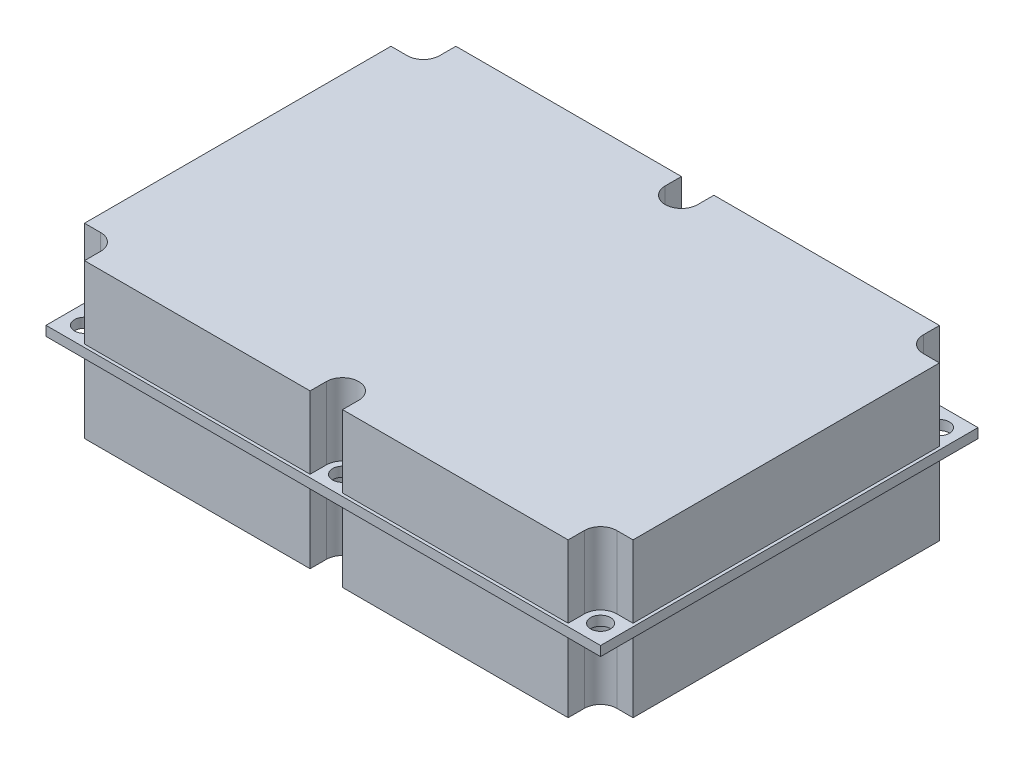
from build123d import *

# Parameters (mm, degrees)
SKETCH1_W            = 91.44
SKETCH1_H            = 62.23
BOSS_EXTRUDE1_DEPTH  = 0.79375
SKETCH3_R            = 1.6383
CUT_EXTRUDE1_DEPTH   = 1.79375
LPATTERN1_COUNT      = 3
LPATTERN1_PITCH      = 42.545
LPATTERN1_COUNT_DIR2 = 2
LPATTERN1_PITCH_DIR2 = 55.88
BOSS_EXTRUDE2_DEPTH  = 12.7


with BuildPart() as part:
    # Sketch1 → Boss-Extrude1 (new body, symmetric)
    with BuildSketch(Plane(origin=(0, 0, 0), x_dir=(1, 0, 0), z_dir=(0, 1, 0))):
        Rectangle(SKETCH1_W, SKETCH1_H)
    extrude(amount=BOSS_EXTRUDE1_DEPTH, both=True)

    # Sketch3 → Cut-Extrude1 (cut, symmetric)
    with BuildSketch(Plane(origin=(0, 0, 0), x_dir=(1, 0, 0), z_dir=(0, 1, 0))):
        with Locations((-42.545, 27.94)):
            Circle(SKETCH3_R)
    cut_extrude1 = extrude(amount=CUT_EXTRUDE1_DEPTH, both=True, mode=Mode.SUBTRACT)

    # LPattern1: Cut-Extrude1 3 × 2
    with Locations(*[(i * LPATTERN1_PITCH, 0, j * LPATTERN1_PITCH_DIR2) for i in range(LPATTERN1_COUNT) for j in range(LPATTERN1_COUNT_DIR2) if (i, j) != (0, 0)]):
        add(cut_extrude1, mode=Mode.SUBTRACT)


with BuildPart() as body_2:
    # Sketch2 → Boss-Extrude2 (new body, symmetric)
    with BuildSketch(Plane(origin=(0, 0, 0), x_dir=(1, 0, 0), z_dir=(0, 1, 0))):
        with BuildLine():
            Line((-42.545, 25.265), (-45.22, 25.265))
            Line((-45.22, 25.265), (-45.22, -25.265))
            Line((-45.22, -25.265), (-42.545, -25.265))
            ThreePointArc((-42.545, -25.265), (-40.65348936, -26.04848936), (-39.87, -27.94))
            Line((-39.87, -27.94), (-39.87, -30.615))
            Line((-39.87, -30.615), (-2.675, -30.615))
            Line((-2.675, -30.615), (-2.675, -27.94))
            ThreePointArc((-2.675, -27.94), (0, -25.265), (2.675, -27.94))
            Line((2.675, -27.94), (2.675, -30.615))
            Line((2.675, -30.615), (39.87, -30.615))
            Line((39.87, -30.615), (39.87, -27.94))
            ThreePointArc((39.87, -27.94), (40.65348936, -26.04848936), (42.545, -25.265))
            Line((42.545, -25.265), (45.22, -25.265))
            Line((45.22, -25.265), (45.22, 25.265))
            Line((45.22, 25.265), (42.545, 25.265))
            ThreePointArc((42.545, 25.265), (40.65348936, 26.04848936), (39.87, 27.94))
            Line((39.87, 27.94), (39.87, 30.615))
            Line((39.87, 30.615), (2.675, 30.615))
            Line((2.675, 30.615), (2.675, 27.94))
            ThreePointArc((2.675, 27.94), (0, 25.265), (-2.675, 27.94))
            Line((-2.675, 27.94), (-2.675, 30.615))
            Line((-2.675, 30.615), (-39.87, 30.615))
            Line((-39.87, 30.615), (-39.87, 27.94))
            ThreePointArc((-39.87, 27.94), (-40.65348936, 26.04848936), (-42.545, 25.265))
        make_face()
    extrude(amount=BOSS_EXTRUDE2_DEPTH, both=True)


solid = Compound([part.part, body_2.part])
